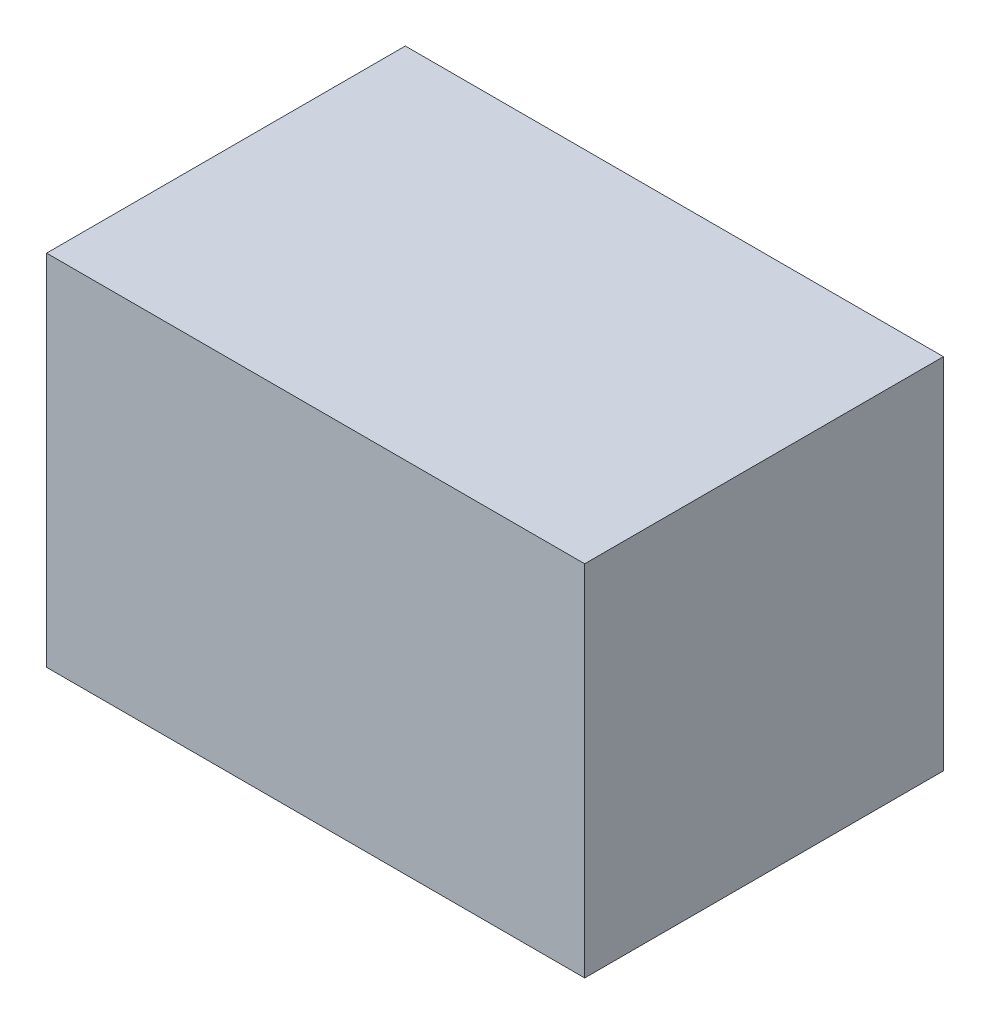
from build123d import *

# Parameters (mm, degrees)
SKETCH2_W           = 457.2
SKETCH2_H           = 304.8
BOSS_EXTRUDE1_DEPTH = 304.8


with BuildPart() as part:
    # Sketch2 → Boss-Extrude1 (new body)
    with BuildSketch(Plane(origin=(0, 0, 0), x_dir=(1, 0, 0), z_dir=(0, 1, 0))):
        Rectangle(SKETCH2_W, SKETCH2_H)
    extrude(amount=BOSS_EXTRUDE1_DEPTH)


solid = part.part
